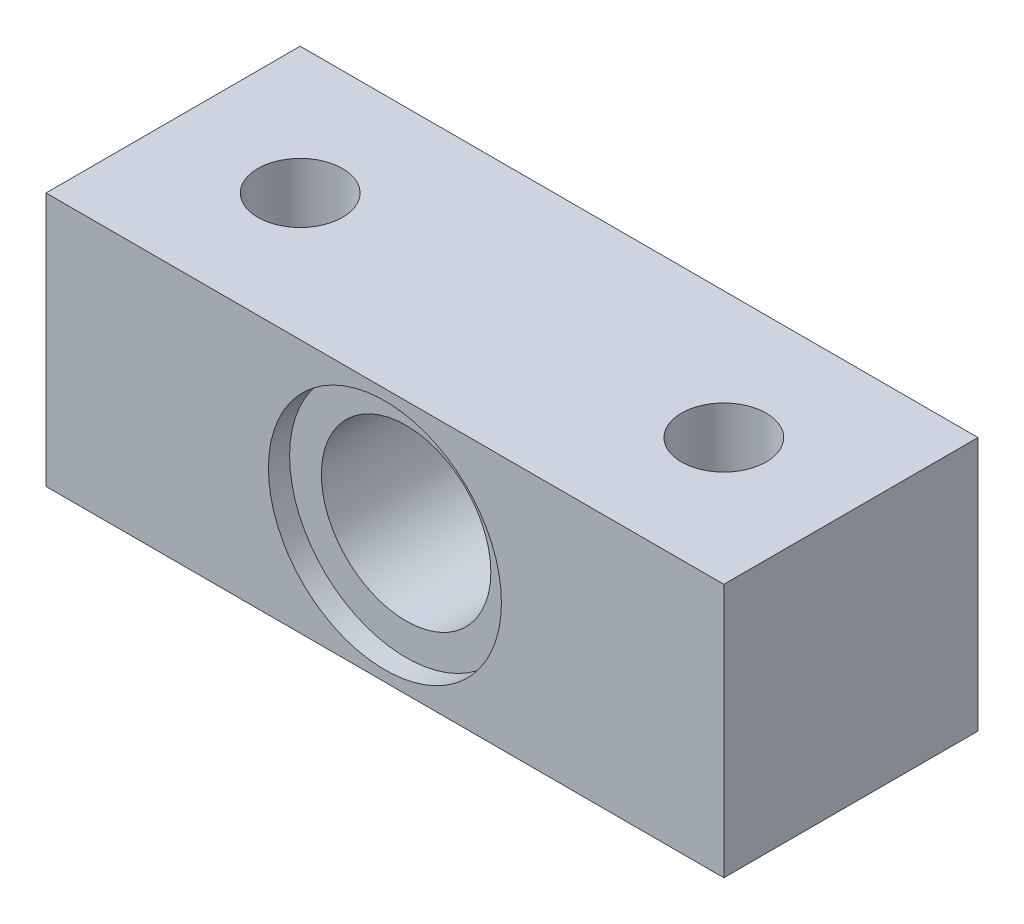
from build123d import *

# Parameters (mm, degrees)
SKETCH1_W           = 50.8
SKETCH1_H           = 19.05
SKETCH1_R           = 6.35
BOSS_EXTRUDE1_DEPTH = 19.05
SKETCH2_R           = 8.73125
CUT_EXTRUDE1_DEPTH  = 1.5875
SKETCH3_R           = 3.175
CUT_EXTRUDE2_DEPTH  = 22.4155
SKETCH4_R           = 4.7625
CUT_EXTRUDE3_DEPTH  = 6.35


with BuildPart() as part:
    # Sketch1 → Boss-Extrude1 (new body)
    with BuildSketch(Plane.XY):
        Rectangle(SKETCH1_W, SKETCH1_H)
        Circle(SKETCH1_R, mode=Mode.SUBTRACT)
    extrude(amount=BOSS_EXTRUDE1_DEPTH)

    # Sketch2 → Cut-Extrude1 (cut)
    with BuildSketch(Plane.XY.offset(19.05)):
        Circle(SKETCH2_R)
    extrude(amount=-CUT_EXTRUDE1_DEPTH, mode=Mode.SUBTRACT)

    # Sketch3 → Cut-Extrude2 (cut)
    with BuildSketch(Plane.XZ.offset(9.525)):
        with Locations((-15.875, 9.525)):
            Circle(SKETCH3_R)
        with Locations((15.875, 9.525)):
            Circle(SKETCH3_R)
    extrude(amount=-CUT_EXTRUDE2_DEPTH, mode=Mode.SUBTRACT)

    # Sketch4 → Cut-Extrude3 (cut)
    with BuildSketch(Plane.XZ.offset(9.525)):
        with Locations((-15.875, 9.525)):
            Circle(SKETCH4_R)
        with Locations((15.875, 9.525)):
            Circle(SKETCH4_R)
    extrude(amount=-CUT_EXTRUDE3_DEPTH, mode=Mode.SUBTRACT)


solid = part.part
